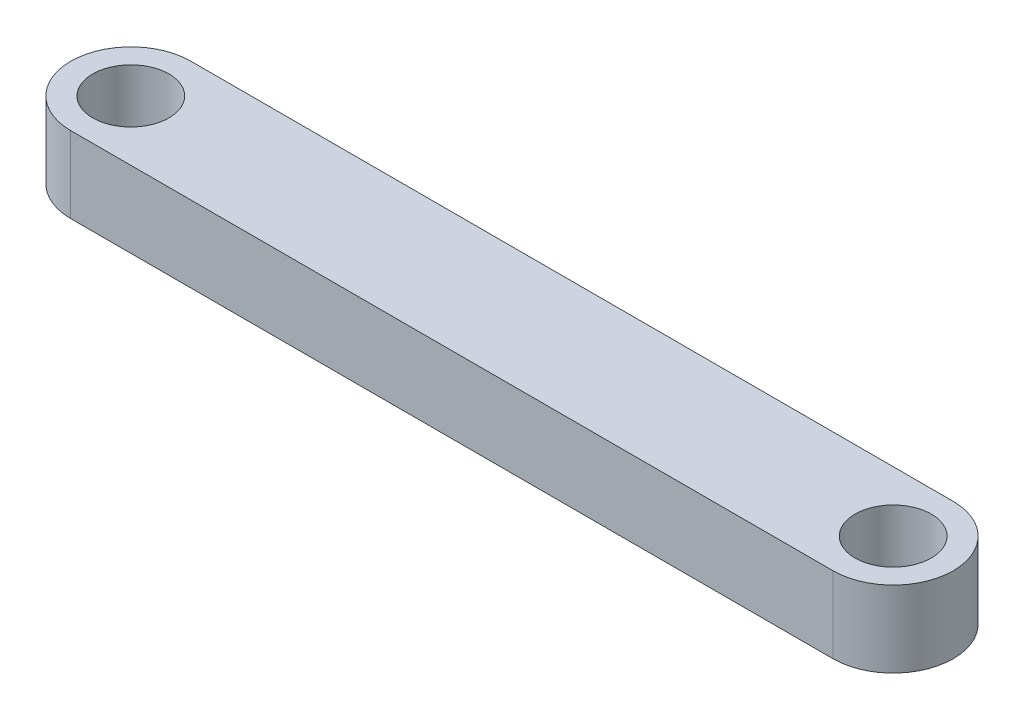
from build123d import *

# Parameters (mm, degrees)
SKETCH1_R           = 1.5
BOSS_EXTRUDE1_DEPTH = 3


with BuildPart() as part:
    # Sketch1 → Boss-Extrude1 (new body)
    with BuildSketch(Plane(origin=(0, 0, 0), x_dir=(1, 0, 0), z_dir=(0, 1, 0))):
        with BuildLine():
            Line((-15, -2.365001907), (15, -2.365001907))
            ThreePointArc((15, -2.365001907), (17.365001907, 0), (15, 2.365001907))
            Line((15, 2.365001907), (-15, 2.365001907))
            ThreePointArc((-15, 2.365001907), (-17.365001907, 0), (-15, -2.365001907))
        make_face()
        with Locations((15, 0)):
            Circle(SKETCH1_R, mode=Mode.SUBTRACT)
        with Locations((-15, 0)):
            Circle(SKETCH1_R, mode=Mode.SUBTRACT)
    extrude(amount=BOSS_EXTRUDE1_DEPTH)


solid = part.part
